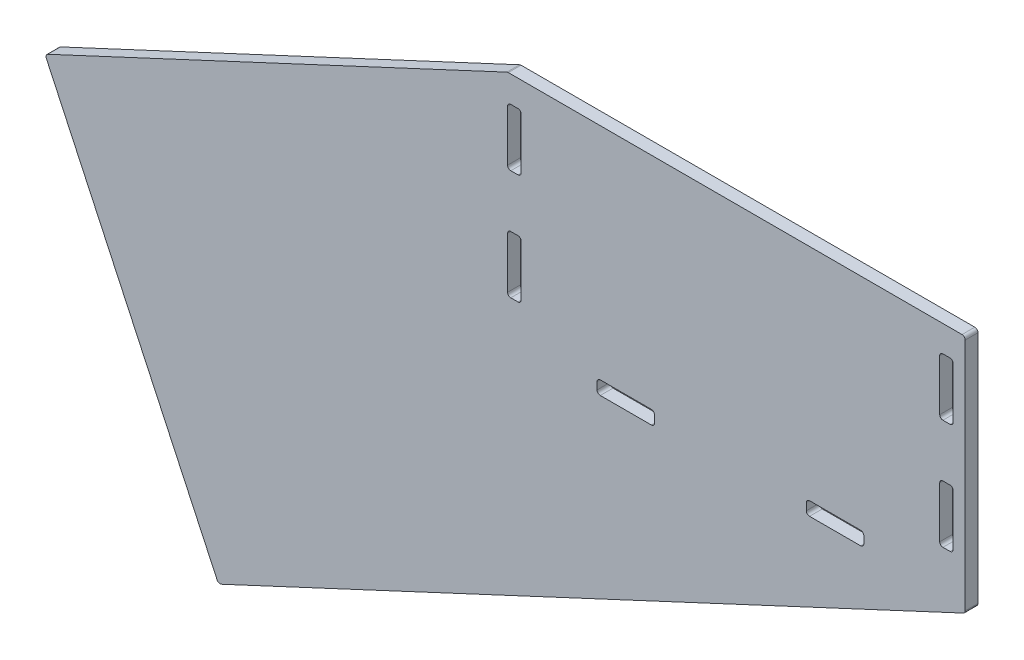
from build123d import *

# Parameters (mm, degrees)
SKETCH1_W           = 416.56
SKETCH1_H           = 219.075
BOSS_EXTRUDE1_DEPTH = 6.35
BOSS_EXTRUDE2_DEPTH = 6.35
FILLET1_R           = 3.175


with BuildPart() as part:
    # Sketch1 → Boss-Extrude1 (new body, symmetric)
    with BuildSketch(Plane.XY):
        with Locations((0, -109.5375)):
            Rectangle(SKETCH1_W, SKETCH1_H)
    extrude(amount=BOSS_EXTRUDE1_DEPTH, both=True)

    # Sketch2 → Boss-Extrude2 (add, symmetric)
    with BuildSketch(Plane.XY):
        Polygon((-221.742, 0), (-682.146355815, -214.690076964), (-509.434106267, -585.072691377), (233.68, -238.552892741), (233.68, 0), (208.28, 0), (208.28, -26.19375), (221.742, -26.19375), (221.742, -83.34375), (208.28, -83.34375), (208.28, -135.73125), (221.742, -135.73125), (221.742, -192.88125), (208.28, -192.88125), (208.28, -219.075), (132.715, -219.075), (132.715, -232.537), (75.565, -232.537), (75.565, -219.075), (-75.565, -219.075), (-75.565, -232.537), (-132.715, -232.537), (-132.715, -219.075), (-208.28, -219.075), (-208.28, -192.88125), (-221.742, -192.88125), (-221.742, -135.73125), (-208.28, -135.73125), (-208.28, -83.34375), (-221.742, -83.34375), (-221.742, -26.19375), (-208.28, -26.19375), (-208.28, 0), align=None)
    extrude(amount=BOSS_EXTRUDE2_DEPTH, both=True)

    # Fillet1
    fillet1_edges = [part.edges().sort_by_distance(p)[0] for p in [
        (-682.146355815, -214.690076964, 0),
        (-509.434106267, -585.072691377, 0),
        (233.68, -238.552892741, 0),
        (233.68, 0, 0),
        (208.28, -26.19375, 0),
        (221.742, -26.19375, 0),
        (221.742, -83.34375, 0),
        (208.28, -83.34375, 0),
        (208.28, -135.73125, 0),
        (221.742, -135.73125, 0),
        (221.742, -192.88125, 0),
        (208.28, -192.88125, 0),
        (132.715, -219.075, 0),
        (132.715, -232.537, 0),
        (75.565, -232.537, 0),
        (75.565, -219.075, 0),
        (-75.565, -219.075, 0),
        (-75.565, -232.537, 0),
        (-132.715, -232.537, 0),
        (-132.715, -219.075, 0),
        (-208.28, -192.88125, 0),
        (-221.742, -192.88125, 0),
        (-221.742, -135.73125, 0),
        (-208.28, -135.73125, 0),
        (-208.28, -83.34375, 0),
        (-221.742, -83.34375, 0),
        (-221.742, -26.19375, 0),
        (-208.28, -26.19375, 0),
        (-221.742, 0, 0),
    ]]
    fillet(fillet1_edges, radius=FILLET1_R)


solid = part.part
